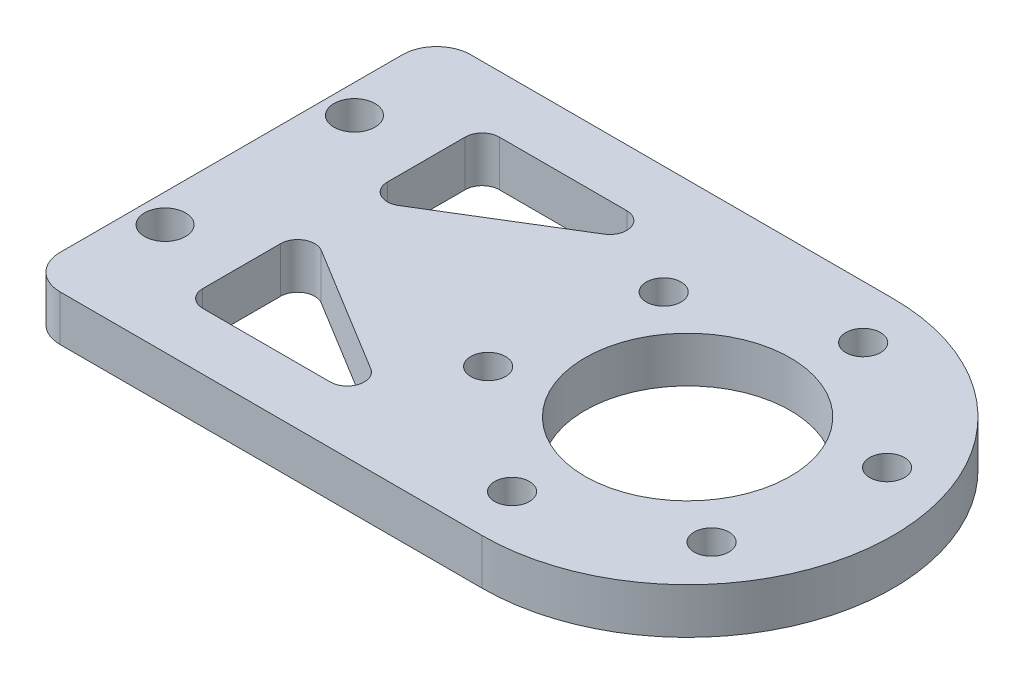
from build123d import *

# Parameters (mm, degrees)
EXTRUDE_1_DEPTH        = 4
SKETCH_2_R             = 1.525
CUT_EXTRUDE_1_DEPTH    = 5
FILLET_1_R             = 3
SKETCH_3_R             = 1.8
CUT_EXTRUDE_5_DEPTH    = 5
CUT_EXTRUDE_3_DEPTH    = 5
FILLET_2_R             = 1.5
FILLET_2_OF_MIRROR_1_R = 1.5
SKETCH_5_R             = 9
CUT_EXTRUDE_4_DEPTH    = 5


with BuildPart() as part:
    # 草图1 → 凸台-拉伸1 (new body)
    with BuildSketch(Plane(origin=(0, 0, 0), x_dir=(1, 0, 0), z_dir=(0, 1, 0))):
        with BuildLine():
            Line((-20, 18), (-20, -18))
            Line((-20, -18), (20, -18))
            ThreePointArc((20, -18), (2, 0), (20, 18))
            Line((20, 18), (-20, 18))
        make_face()
        with BuildLine():
            ThreePointArc((20, 18), (2, 0), (20, -18))
            Line((20, -18), (20, 18))
        make_face()
        with BuildLine():
            Line((20, 18), (20, -18))
            ThreePointArc((20, -18), (32.727922061, -12.727922061), (38, 0))
            ThreePointArc((38, 0), (32.727922061, 12.727922061), (20, 18))
        make_face()
    extrude(amount=EXTRUDE_1_DEPTH)

    # 草图2 → 切除-拉伸1 (cut, through all)
    with BuildSketch(Plane(origin=(0, 4, 0), x_dir=(1, 0, 0), z_dir=(0, 1, 0))):
        with Locations((9.463257492, 8.439612392)):
            Circle(SKETCH_2_R)
        with Locations((7.422710017, -4.905280489)):
            Circle(SKETCH_2_R)
        with Locations((30.536742508, -8.439612392)):
            Circle(SKETCH_2_R)
        with Locations((17.959452524, -13.344892881)):
            Circle(SKETCH_2_R)
        with Locations((32.577289983, 4.905280489)):
            Circle(SKETCH_2_R)
        with Locations((22.040547476, 13.344892881)):
            Circle(SKETCH_2_R)
    extrude(amount=-CUT_EXTRUDE_1_DEPTH, mode=Mode.SUBTRACT)

    # 圆角1
    fillet_1_edges = [part.edges().sort_by_distance(p)[0] for p in [
        (-20, 2, 18),
        (-20, 2, -18),
    ]]
    fillet(fillet_1_edges, radius=FILLET_1_R)

    # 草图3 → 切除-拉伸5 (cut, through all)
    with BuildSketch(Plane(origin=(0, 4, 0), x_dir=(1, 0, 0), z_dir=(0, 1, 0))):
        with Locations((-17.5, -8.3)):
            Circle(SKETCH_3_R)
        with Locations((-17.5, 8.3)):
            Circle(SKETCH_3_R)
    extrude(amount=-CUT_EXTRUDE_5_DEPTH, mode=Mode.SUBTRACT)

    # 草图4 → 切除-拉伸3 (cut, through all)
    with BuildSketch(Plane(origin=(0, 4, 0), x_dir=(1, 0, 0), z_dir=(0, 1, 0))):
        Polygon((-11, 2), (-11, 13), (7, 13), align=None)
    cut_extrude_3 = extrude(amount=-CUT_EXTRUDE_3_DEPTH, mode=Mode.SUBTRACT)

    # 圆角2
    fillet_2_edges = [part.edges().sort_by_distance(p)[0] for p in [
        (-11, 2, -2),
        (-11, 2, -13),
        (7, 2, -13),
    ]]
    fillet(fillet_2_edges, radius=FILLET_2_R)

    # 镜向1: 切除-拉伸3 across plane
    add(cut_extrude_3.mirror(Plane.XY), mode=Mode.SUBTRACT)

    # 圆角2 of 镜向1
    fillet_2_of_mirror_1_edges = [part.edges().sort_by_distance(p)[0] for p in [
        (-11, 2, 2),
        (-11, 2, 13),
        (7, 2, 13),
    ]]
    fillet(fillet_2_of_mirror_1_edges, radius=FILLET_2_OF_MIRROR_1_R)

    # 草图5 → 切除-拉伸4 (cut, through all)
    with BuildSketch(Plane(origin=(0, 4, 0), x_dir=(1, 0, 0), z_dir=(0, 1, 0))):
        with Locations((20, 0)):
            Circle(SKETCH_5_R)
    extrude(amount=-CUT_EXTRUDE_4_DEPTH, mode=Mode.SUBTRACT)


solid = part.part
